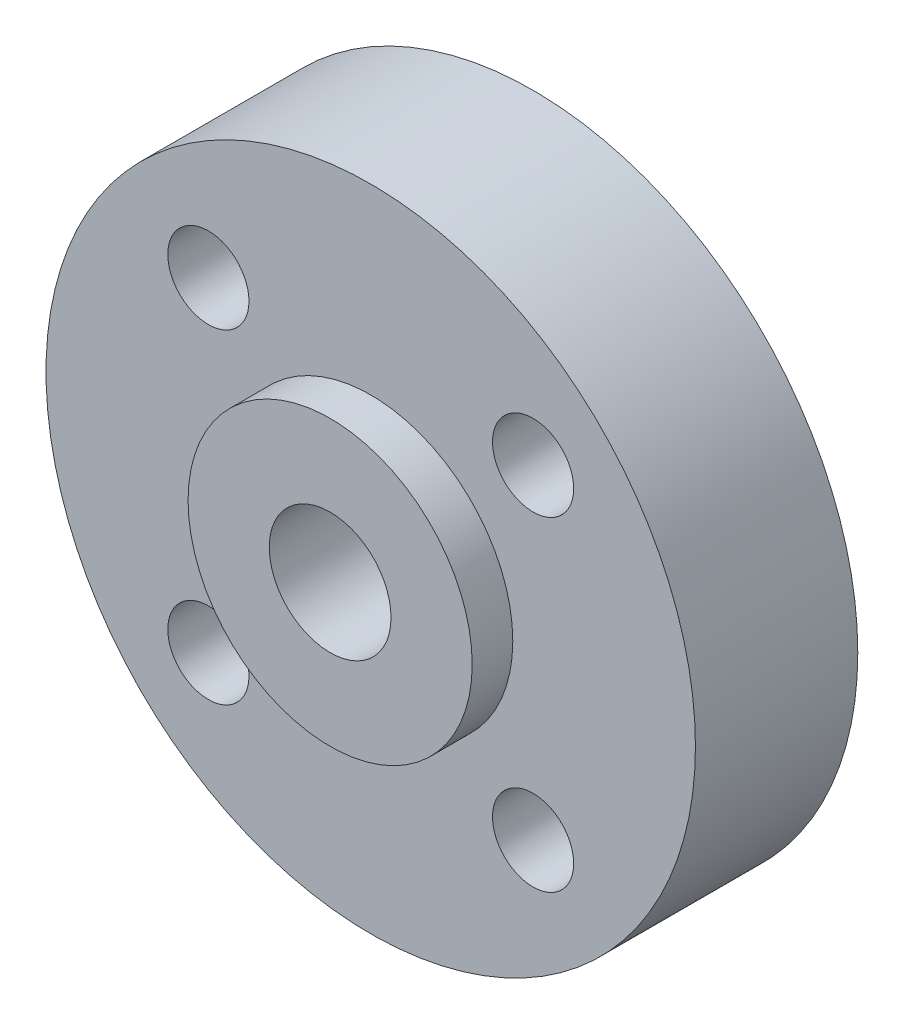
from build123d import *

# Parameters (mm, degrees)
SKETCH_1_R          = 16
EXTRUDE_1_DEPTH     = 8
SKETCH_2_R          = 7
EXTRUDE_2_DEPTH     = 2
SKETCH_3_R          = 2
CUT_EXTRUDE_1_DEPTH = 20
SKETCH_4_R          = 3
CUT_EXTRUDE_2_DEPTH = 20


with BuildPart() as part:
    # 草图1 → 凸台-拉伸1 (new body)
    with BuildSketch(Plane.XY):
        Circle(SKETCH_1_R)
    extrude(amount=EXTRUDE_1_DEPTH)

    # 草图2 → 凸台-拉伸2 (add)
    with BuildSketch(Plane.XY.offset(8)):
        Circle(SKETCH_2_R)
    extrude(amount=EXTRUDE_2_DEPTH)

    # 草图3 → 切除-拉伸1 (cut)
    with BuildSketch(Plane.XY.offset(8)):
        with Locations((-8, 8)):
            Circle(SKETCH_3_R)
        with Locations((8, 8)):
            Circle(SKETCH_3_R)
        with Locations((8, -8)):
            Circle(SKETCH_3_R)
        with Locations((-8, -8)):
            Circle(SKETCH_3_R)
    extrude(amount=-CUT_EXTRUDE_1_DEPTH, mode=Mode.SUBTRACT)

    # 草图4 → 切除-拉伸2 (cut)
    with BuildSketch(Plane.XY.offset(10)):
        Circle(SKETCH_4_R)
    extrude(amount=-CUT_EXTRUDE_2_DEPTH, mode=Mode.SUBTRACT)


solid = part.part
